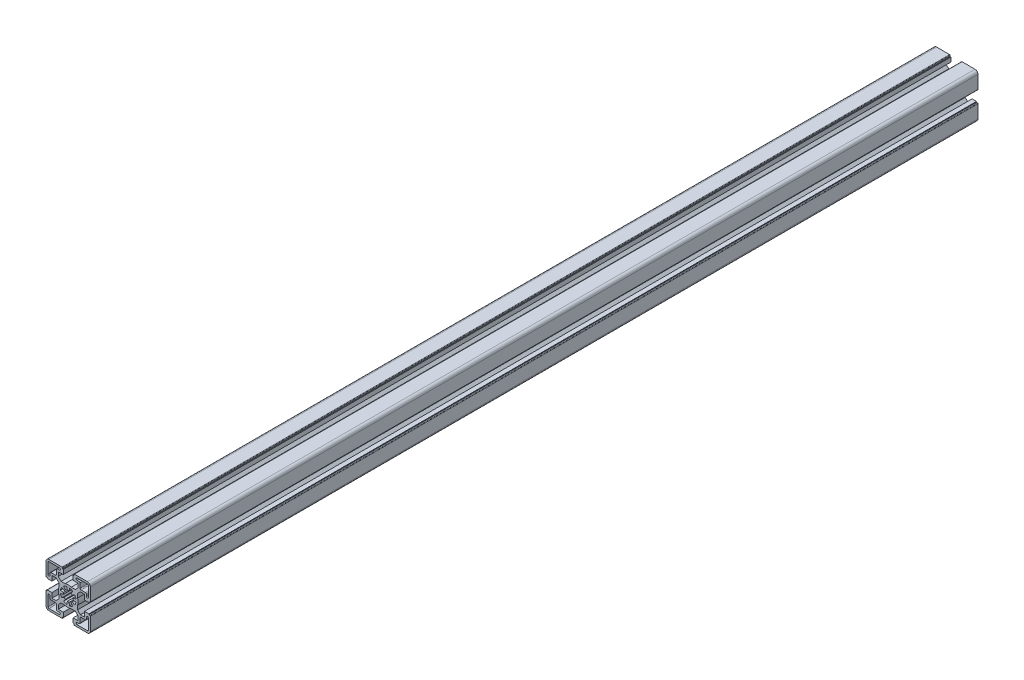
from build123d import *

# Parameters (mm, degrees)
BASE_EXTRUDE_DEPTH = 900


with BuildPart() as part:
    # Sketch1 → Base-Extrude (new body)
    with BuildSketch(Plane.XY):
        with BuildLine():
            Line((-4.99999574, -16.499883971), (-4.99999574, -20.99990968))
            Line((-4.99999574, -20.99990968), (-5.80004044, -20.99990968))
            Line((-5.80004044, -20.99990968), (-5.80004044, -21.999970054))
            ThreePointArc((-5.80004044, -21.999970054), (-5.946487232, -22.353523887), (-6.300041066, -22.49997068))
            Line((-6.300041066, -22.49997068), (-19.500014911, -22.49997068))
            ThreePointArc((-19.500014911, -22.49997068), (-21.62133367, -21.62129168), (-22.50001267, -19.499972921))
            Line((-22.50001267, -19.499972921), (-22.50001267, -6.299929564))
            ThreePointArc((-22.50001267, -6.299929564), (-22.353566213, -5.946376541), (-22.00001319, -5.799930084))
            Line((-22.00001319, -5.799930084), (-21.000012806, -5.799930084))
            Line((-21.000012806, -5.799930084), (-21.000012806, -4.999940084))
            Line((-21.000012806, -4.999940084), (-16.500012806, -4.999940084))
            Line((-16.500012806, -4.999940084), (-16.500012806, -10.049940084))
            Line((-16.500012806, -10.049940084), (-12.342923806, -10.049940084))
            Line((-12.342923806, -10.049940084), (-9.499953806, -7.206970084))
            Line((-9.499953806, -7.206970084), (-9.499953806, -3.122617084))
            ThreePointArc((-9.499953806, -3.122617084), (-10.000013376, 6.1916e-05), (-9.499953806, 3.122740916))
            Line((-9.499953806, 3.122740916), (-9.499953806, 7.206970084))
            Line((-9.499953806, 7.206970084), (-12.342923806, 10.049940084))
            Line((-12.342923806, 10.049940084), (-16.500012806, 10.049940084))
            Line((-16.500012806, 10.049940084), (-16.500012806, 4.999940084))
            Line((-16.500012806, 4.999940084), (-21.000012806, 4.999940084))
            Line((-21.000012806, 4.999940084), (-21.000012806, 5.799930084))
            Line((-21.000012806, 5.799930084), (-22.00001319, 5.799930084))
            ThreePointArc((-22.00001319, 5.799930084), (-22.353566213, 5.946376541), (-22.50001267, 6.299929564))
            Line((-22.50001267, 6.299929564), (-22.50001267, 19.499972921))
            ThreePointArc((-22.50001267, 19.499972921), (-21.62133367, 21.62129168), (-19.500014911, 22.49997068))
            Line((-19.500014911, 22.49997068), (-6.299954884, 22.49997068))
            ThreePointArc((-6.299954884, 22.49997068), (-5.946364566, 22.353508775), (-5.799902661, 21.999918456))
            Line((-5.799902661, 21.999918456), (-5.799902661, 20.999918083))
            Line((-5.799902661, 20.999918083), (-4.99999574, 20.999918083))
            Line((-4.99999574, 20.999918083), (-4.99999574, 16.499989166))
            Line((-4.99999574, 16.499989166), (-10.050086009, 16.499989166))
            Line((-10.050086009, 16.499989166), (-10.050086009, 12.342794971))
            Line((-10.050086009, 12.342794971), (-7.207151696, 9.499860659))
            Line((-7.207151696, 9.499860659), (-3.122798696, 9.499860659))
            ThreePointArc((-3.122798696, 9.499860659), (-0.000120196, 9.999920064), (3.122558304, 9.499860659))
            Line((3.122558304, 9.499860659), (7.206958901, 9.499860659))
            Line((7.206958901, 9.499860659), (10.049884116, 12.342787874))
            Line((10.049884116, 12.342787874), (10.049884116, 16.499989166))
            Line((10.049884116, 16.499989166), (4.99999574, 16.499989166))
            Line((4.99999574, 16.499989166), (4.99999574, 20.999963909))
            Line((4.99999574, 20.999963909), (5.799902661, 20.999963909))
            Line((5.799902661, 20.999963909), (5.799902661, 21.999918456))
            ThreePointArc((5.799902661, 21.999918456), (5.946364566, 22.353508775), (6.299954884, 22.49997068))
            Line((6.299954884, 22.49997068), (19.500081571, 22.49997068))
            ThreePointArc((19.500081571, 22.49997068), (21.62140033, 21.62129168), (22.50007933, 19.499972921))
            Line((22.50007933, 19.499972921), (22.50007933, 6.299877709))
            ThreePointArc((22.50007933, 6.299877709), (22.35363283, 5.946324583), (22.000079704, 5.799878083))
            Line((22.000079704, 5.799878083), (20.999995421, 5.799878083))
            Line((20.999995421, 5.799878083), (20.999995421, 4.999941084))
            Line((20.999995421, 4.999941084), (16.499983596, 4.999941084))
            Line((16.499983596, 4.999941084), (16.499983596, 10.049940084))
            Line((16.499983596, 10.049940084), (12.342894596, 10.049940084))
            Line((12.342894596, 10.049940084), (9.499922596, 7.206970084))
            Line((9.499922596, 7.206970084), (9.499922596, 3.122735916))
            ThreePointArc((9.499922596, 3.122735916), (9.999982165, 5.6916e-05), (9.499922596, -3.122622084))
            Line((9.499922596, -3.122622084), (9.499922596, -7.206970084))
            Line((9.499922596, -7.206970084), (12.342894596, -10.049940084))
            Line((12.342894596, -10.049940084), (16.499983596, -10.049940084))
            Line((16.499983596, -10.049940084), (16.499983596, -4.999941084))
            Line((16.499983596, -4.999941084), (20.999995421, -4.999941084))
            Line((20.999995421, -4.999941084), (20.999995421, -5.799878083))
            Line((20.999995421, -5.799878083), (22.000079704, -5.799878083))
            ThreePointArc((22.000079704, -5.799878083), (22.35363283, -5.946324583), (22.50007933, -6.299877709))
            Line((22.50007933, -6.299877709), (22.50007933, -19.499973421))
            ThreePointArc((22.50007933, -19.499973421), (21.621400476, -21.621291826), (19.500082071, -22.49997068))
            Line((19.500082071, -22.49997068), (6.300041066, -22.49997068))
            ThreePointArc((6.300041066, -22.49997068), (5.946487232, -22.353523887), (5.80004044, -21.999970054))
            Line((5.80004044, -21.999970054), (5.80004044, -20.99990968))
            Line((5.80004044, -20.99990968), (4.99999574, -20.99990968))
            Line((4.99999574, -20.99990968), (4.99999574, -16.499883971))
            Line((4.99999574, -16.499883971), (10.049884116, -16.499883971))
            Line((10.049884116, -16.499883971), (10.049884116, -12.342787874))
            Line((10.049884116, -12.342787874), (7.206933602, -9.49983536))
            Line((7.206933602, -9.49983536), (3.122579602, -9.49983536))
            ThreePointArc((3.122579602, -9.49983536), (-9.9398e-05, -9.99989493), (-3.122778398, -9.49983536))
            Line((-3.122778398, -9.49983536), (-7.207126398, -9.49983536))
            Line((-7.207126398, -9.49983536), (-10.050086009, -12.342794971))
            Line((-10.050086009, -12.342794971), (-10.050086009, -16.499883971))
            Line((-10.050086009, -16.499883971), (-4.99999574, -16.499883971))
        make_face()
        with BuildLine():
            Line((0.868239441, 4.924019626), (1.389186106, 7.878448412))
            ThreePointArc((1.389186106, 7.878448412), (3.061471579, 7.391020172), (4.588617704, 6.553195784))
            Line((4.588617704, 6.553195784), (2.867879873, 4.095738521))
            ThreePointArc((2.867879873, 4.095738521), (3.535523556, 3.535517244), (4.095743641, 2.867872561))
            Line((4.095743641, 2.867872561), (6.553203976, 4.588606005))
            ThreePointArc((6.553203976, 4.588606005), (7.391023332, 3.061463952), (7.878448799, 1.389183909))
            Line((7.878448799, 1.389183909), (4.924019868, 0.868238068))
            ThreePointArc((4.924019868, 0.868238068), (4.9999809, 7.81e-07), (4.924020139, -0.868236529))
            Line((4.924020139, -0.868236529), (7.878449234, -1.389181447))
            ThreePointArc((7.878449234, -1.389181447), (7.391025132, -3.061459606), (6.553207937, -4.588600349))
            Line((6.553207937, -4.588600349), (4.095746117, -2.867869026))
            ThreePointArc((4.095746117, -2.867869026), (3.535522832, -3.535517968), (2.86787466, -4.095742171))
            Line((2.86787466, -4.095742171), (4.588609364, -6.553201624))
            ThreePointArc((4.588609364, -6.553201624), (3.061466598, -7.391022236), (1.389185513, -7.878448517))
            Line((1.389185513, -7.878448517), (0.868239071, -4.924019691))
            ThreePointArc((0.868239071, -4.924019691), (8.15e-07, -4.9999809), (-0.868237465, -4.924019974))
            Line((-0.868237465, -4.924019974), (-1.389182943, -7.87844897))
            ThreePointArc((-1.389182943, -7.87844897), (-3.06146423, -7.391023216), (-4.588607303, -6.553203067))
            Line((-4.588607303, -6.553203067), (-2.867873372, -4.095743073))
            ThreePointArc((-2.867873372, -4.095743073), (-3.535520061, -3.535520739), (-4.095742523, -2.867874158))
            Line((-4.095742523, -2.867874158), (-6.553202186, -4.588608561))
            ThreePointArc((-6.553202186, -4.588608561), (-7.391024272, -3.061461681), (-7.878450195, -1.389175997))
            Line((-7.878450195, -1.389175997), (-4.92402074, -0.868233124))
            ThreePointArc((-4.92402074, -0.868233124), (-4.9999809, 1.729e-06), (-4.924020139, 0.868236529))
            Line((-4.924020139, 0.868236529), (-7.878449234, 1.389181447))
            ThreePointArc((-7.878449234, 1.389181447), (-7.391023494, 3.061463561), (-6.553203027, 4.588607361))
            Line((-6.553203027, 4.588607361), (-4.095743048, 2.867873408))
            ThreePointArc((-4.095743048, 2.867873408), (-3.535525782, 3.535515019), (-2.867885877, 4.095734317))
            Line((-2.867885877, 4.095734317), (-4.588627311, 6.553189058))
            ThreePointArc((-4.588627311, 6.553189058), (-3.061465289, 7.391022778), (-1.389161147, 7.878452813))
            Line((-1.389161147, 7.878452813), (-0.868223842, 4.924022376))
            ThreePointArc((-0.868223842, 4.924022376), (7.92e-06, 4.9999809), (0.868239441, 4.924019626))
        make_face(mode=Mode.SUBTRACT)
        with BuildLine():
            Line((-17.500118733, -12.000017917), (-13.000117238, -12.000017917))
            ThreePointArc((-13.000117238, -12.000017917), (-12.293010985, -12.292910917), (-12.000117985, -13.00001717))
            Line((-12.000117985, -13.00001717), (-12.000117985, -17.49992083))
            ThreePointArc((-12.000117985, -17.49992083), (-11.707224985, -18.207027083), (-11.000118733, -18.499920083))
            Line((-11.000118733, -18.499920083), (-9.000117985, -18.499920083))
            ThreePointArc((-9.000117985, -18.499920083), (-8.000069068, -19.499969), (-9.000117985, -20.500017917))
            Line((-9.000117985, -20.500017917), (-19.500118733, -20.500017917))
            ThreePointArc((-19.500118733, -20.500017917), (-20.207224985, -20.207124917), (-20.500117985, -19.500018664))
            Line((-20.500117985, -19.500018664), (-20.500117985, -8.999920083))
            ThreePointArc((-20.500117985, -8.999920083), (-19.500117985, -7.999920083), (-18.500117985, -8.999920083))
            Line((-18.500117985, -8.999920083), (-18.500117985, -11.000018664))
            ThreePointArc((-18.500117985, -11.000018664), (-18.207224985, -11.707124917), (-17.500118733, -12.000017917))
        make_face(mode=Mode.SUBTRACT)
        with BuildLine():
            Line((13.000003267, -12.000017917), (17.500004762, -12.000017917))
            ThreePointArc((17.500004762, -12.000017917), (18.207111015, -11.707124917), (18.500004015, -11.000018664))
            Line((18.500004015, -11.000018664), (18.500004015, -9.000115751))
            ThreePointArc((18.500004015, -9.000115751), (19.500004015, -8.000115751), (20.500004015, -9.000115751))
            Line((20.500004015, -9.000115751), (20.500004015, -19.500018664))
            ThreePointArc((20.500004015, -19.500018664), (20.207111015, -20.207124917), (19.500004762, -20.500017917))
            Line((19.500004762, -20.500017917), (9.000004015, -20.500017917))
            ThreePointArc((9.000004015, -20.500017917), (7.999955097, -19.499969), (9.000004015, -18.499920083))
            Line((9.000004015, -18.499920083), (11.000004762, -18.499920083))
            ThreePointArc((11.000004762, -18.499920083), (11.707111015, -18.207027083), (12.000004015, -17.49992083))
            Line((12.000004015, -17.49992083), (12.000004015, -13.00001717))
            ThreePointArc((12.000004015, -13.00001717), (12.292897015, -12.292910917), (13.000003267, -12.000017917))
        make_face(mode=Mode.SUBTRACT)
        with BuildLine():
            Line((-17.500118733, 12.000017917), (-13.000117238, 12.000017917))
            ThreePointArc((-13.000117238, 12.000017917), (-12.293010985, 12.292910917), (-12.000117985, 13.00001717))
            Line((-12.000117985, 13.00001717), (-12.000117985, 17.49992083))
            ThreePointArc((-12.000117985, 17.49992083), (-11.707224985, 18.207027083), (-11.000118733, 18.499920083))
            Line((-11.000118733, 18.499920083), (-9.000117985, 18.499920083))
            ThreePointArc((-9.000117985, 18.499920083), (-8.000069068, 19.499969), (-9.000117985, 20.500017917))
            Line((-9.000117985, 20.500017917), (-19.500118733, 20.500017917))
            ThreePointArc((-19.500118733, 20.500017917), (-20.207224985, 20.207124917), (-20.500117985, 19.500018664))
            Line((-20.500117985, 19.500018664), (-20.500117985, 8.999920083))
            ThreePointArc((-20.500117985, 8.999920083), (-19.500117985, 7.999920083), (-18.500117985, 8.999920083))
            Line((-18.500117985, 8.999920083), (-18.500117985, 11.000018664))
            ThreePointArc((-18.500117985, 11.000018664), (-18.207224985, 11.707124917), (-17.500118733, 12.000017917))
        make_face(mode=Mode.SUBTRACT)
        with BuildLine():
            Line((13.000003267, 12.000017917), (17.500004762, 12.000017917))
            ThreePointArc((17.500004762, 12.000017917), (18.207111015, 11.707124917), (18.500004015, 11.000018664))
            Line((18.500004015, 11.000018664), (18.500004015, 9.000115751))
            ThreePointArc((18.500004015, 9.000115751), (19.500004015, 8.000115751), (20.500004015, 9.000115751))
            Line((20.500004015, 9.000115751), (20.500004015, 19.500018664))
            ThreePointArc((20.500004015, 19.500018664), (20.207111015, 20.207124917), (19.500004762, 20.500017917))
            Line((19.500004762, 20.500017917), (9.000004015, 20.500017917))
            ThreePointArc((9.000004015, 20.500017917), (7.999955097, 19.499969), (9.000004015, 18.499920083))
            Line((9.000004015, 18.499920083), (11.000004762, 18.499920083))
            ThreePointArc((11.000004762, 18.499920083), (11.707111015, 18.207027083), (12.000004015, 17.49992083))
            Line((12.000004015, 17.49992083), (12.000004015, 13.00001717))
            ThreePointArc((12.000004015, 13.00001717), (12.292897015, 12.292910917), (13.000003267, 12.000017917))
        make_face(mode=Mode.SUBTRACT)
    extrude(amount=BASE_EXTRUDE_DEPTH)


solid = part.part
